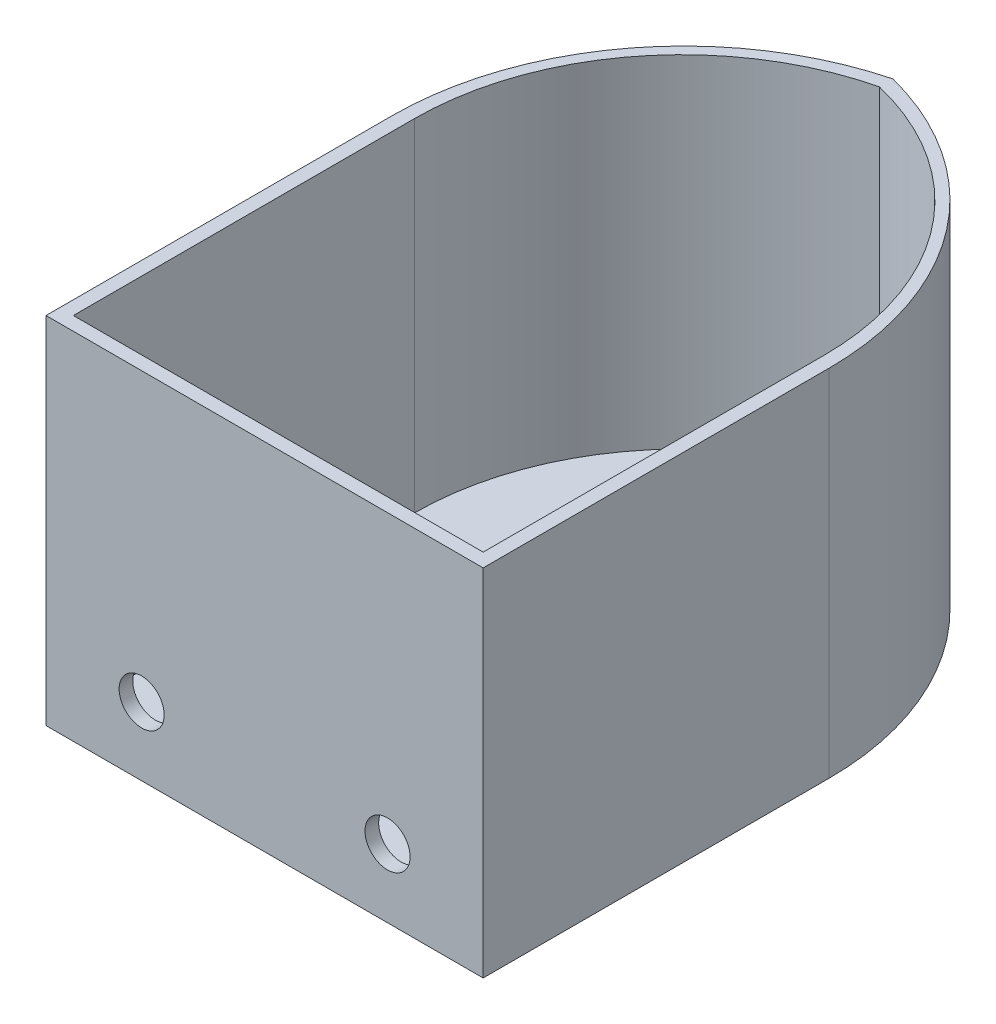
from build123d import *

# Parameters (mm, degrees)
BOSS_EXTRUDE1_DEPTH = 66.04
THICKEN1_T2         = 2.54
SKETCH3_R           = 4.191
CUT_EXTRUDE1_DEPTH  = 2.54


with BuildPart() as part:
    # Sketch1 → Boss-Extrude1 (new body)
    with BuildSketch(Plane(origin=(0, 0, 0), x_dir=(1, 0, 0), z_dir=(0, 1, 0))):
        with BuildLine():
            Line((40.64, 0), (-40.64, 0))
            Line((-40.64, 0), (-40.64, 64.32775415))
            ThreePointArc((-40.64, 64.32775415), (-29.293308759, 97.528452803), (0, 116.84))
            ThreePointArc((0, 116.84), (29.293308759, 97.528452803), (40.64, 64.32775415))
            Line((40.64, 64.32775415), (40.64, 0))
        make_face()
        with BuildLine():
            Line((-38.1, 2.54), (38.1, 2.54))
            Line((38.1, 2.54), (38.1, 65.938950101))
            ThreePointArc((38.1, 65.938950101), (27.430794734, 96.722067013), (0, 114.3))
            ThreePointArc((0, 114.3), (-27.430794734, 96.722067013), (-38.1, 65.938950101))
            Line((-38.1, 65.938950101), (-38.1, 2.54))
        make_face(mode=Mode.SUBTRACT)
    extrude(amount=BOSS_EXTRUDE1_DEPTH)

    # Sketch2 → Surface-Plane1: a flat surface bounded by the sketch
    with BuildSketch(Plane.XZ, mode=Mode.PRIVATE) as surface_plane1_1_region:
        with BuildLine():
            Line((-40.64, 0), (40.64, 0))
            Line((40.64, 0), (40.64, -64.32775415))
            ThreePointArc((40.64, -64.32775415), (29.293308759, -97.528452803), (0, -116.84))
            ThreePointArc((0, -116.84), (-29.293308759, -97.528452803), (-40.64, -64.32775415))
            Line((-40.64, -64.32775415), (-40.64, 0))
        make_face()
    surface_plane1_1 = surface_plane1_1_region.sketch.faces()[0]
    add(Solid.thicken(surface_plane1_1, -THICKEN1_T2))

    # Sketch3 → Cut-Extrude1 (cut)
    with BuildSketch(Plane.XY):
        with Locations((22.86, 12.7)):
            Circle(SKETCH3_R)
        with Locations((-22.86, 12.7)):
            Circle(SKETCH3_R)
    extrude(amount=-CUT_EXTRUDE1_DEPTH, mode=Mode.SUBTRACT)


solid = part.part
